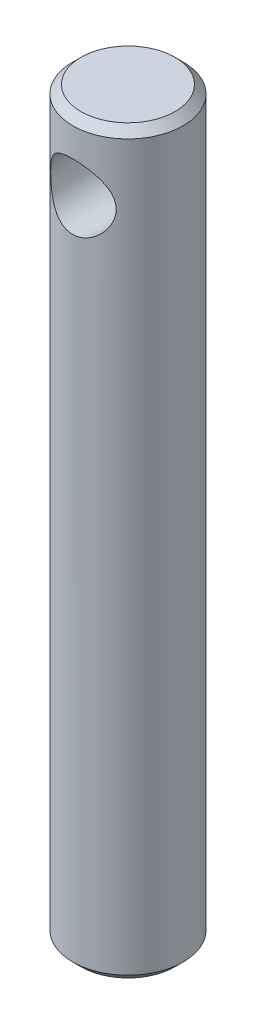
from build123d import *

# Parameters (mm, degrees)
SKETCH1_R               = 13.5
BOSS_EXTRUDE1_DEPTH     = 181
CUT_EXTRUDE1_DEPTH      = 183.004120832
CUT_EXTRUDE1_DEPTH_BACK = 183.004120832
SKETCH2_R               = 8
CHAMFER1_SIZE           = 2


with BuildPart() as part:
    # Sketch1 → Boss-Extrude1 (new body)
    with BuildSketch(Plane(origin=(0, 0, 0), x_dir=(1, 0, 0), z_dir=(0, 1, 0))):
        Circle(SKETCH1_R)
    extrude(amount=BOSS_EXTRUDE1_DEPTH)

    # Sketch2 → Cut-Extrude1 (cut, two sides: drawn at the far end of the back side and taken through both)
    with BuildSketch(Plane.XY.offset(-CUT_EXTRUDE1_DEPTH_BACK)):
        with Locations((0, 164)):
            Circle(SKETCH2_R)
    extrude(amount=CUT_EXTRUDE1_DEPTH + CUT_EXTRUDE1_DEPTH_BACK, mode=Mode.SUBTRACT)

    # Chamfer1
    chamfer1_edges = [part.edges().sort_by_distance(p)[0] for p in [
        (-13.5, 181, 0),
        (-13.5, 0, 0),
    ]]
    chamfer(chamfer1_edges, length=CHAMFER1_SIZE)


solid = part.part
